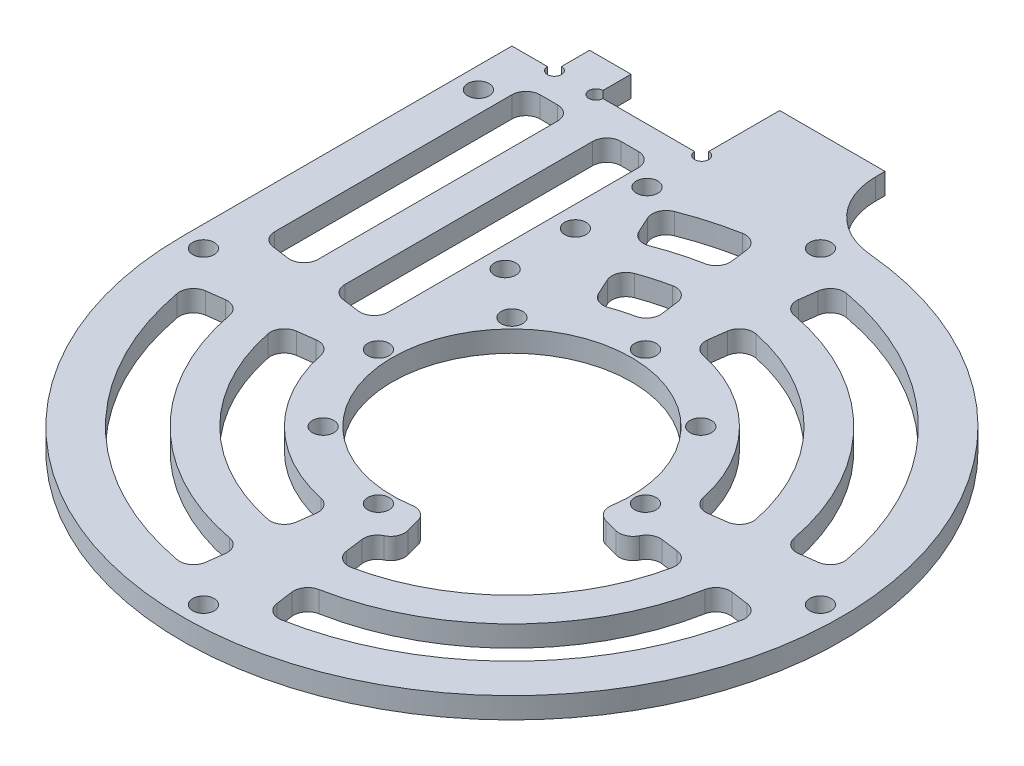
from build123d import *

# Parameters (mm, degrees)
SKETCH_1_R          = 1.525
SKETCH_1_R_2        = 17.025
EXTRUDE_1_DEPTH     = 3
CUT_EXTRUDE_2_DEPTH = 4
CUT_EXTRUDE_3_DEPTH = 4
FILLET_1_R          = 2
SKETCH_5_W          = 5.9
SKETCH_5_H          = 5
EXTRUDE_3_DEPTH     = 3
FILLET_3_R          = 10
SKETCH_6_R          = 1
CUT_EXTRUDE_7_DEPTH = 4.0000001


with BuildPart() as part:
    # 草图1 → 凸台-拉伸1 (new body)
    with BuildSketch(Plane(origin=(0, 0, 0), x_dir=(1, 0, 0), z_dir=(0, 1, 0))):
        with BuildLine():
            Line((-46.9, 0), (-46.9, 46.9))
            Line((-46.9, 46.9), (-16.9, 46.9))
            Line((-16.9, 46.9), (-16.9, 46.574671228))
            ThreePointArc((-16.9, 46.574671228), (-16.079234093, 44.95930534), (-14.290593047, 44.669776699))
            ThreePointArc((-14.290593047, 44.669776699), (37.88033008, -27.65303949), (-46.9, 0))
        make_face()
        with Locations((-19.9, 39.130550724)):
            Circle(SKETCH_1_R, mode=Mode.SUBTRACT)
        with Locations((0, 43.9)):
            Circle(SKETCH_1_R, mode=Mode.SUBTRACT)
        with Locations((43.9, 0)):
            Circle(SKETCH_1_R, mode=Mode.SUBTRACT)
        with Locations((0, -43.9)):
            Circle(SKETCH_1_R, mode=Mode.SUBTRACT)
        with Locations((-43.9, 0)):
            Circle(SKETCH_1_R, mode=Mode.SUBTRACT)
        Circle(SKETCH_1_R_2, mode=Mode.SUBTRACT)
        with Locations((0, 19)):
            Circle(SKETCH_1_R, mode=Mode.SUBTRACT)
        with Locations((13.435028843, 13.435028843)):
            Circle(SKETCH_1_R, mode=Mode.SUBTRACT)
        with Locations((19, 0)):
            Circle(SKETCH_1_R, mode=Mode.SUBTRACT)
        with Locations((13.435028843, -13.435028843)):
            Circle(SKETCH_1_R, mode=Mode.SUBTRACT)
        with Locations((0, -19)):
            Circle(SKETCH_1_R, mode=Mode.SUBTRACT)
        with Locations((-13.435028843, -13.435028843)):
            Circle(SKETCH_1_R, mode=Mode.SUBTRACT)
        with Locations((-19, 0)):
            Circle(SKETCH_1_R, mode=Mode.SUBTRACT)
        with Locations((-13.435028843, 13.435028843)):
            Circle(SKETCH_1_R, mode=Mode.SUBTRACT)
        with Locations((-43.9, 39.130550724)):
            Circle(SKETCH_1_R, mode=Mode.SUBTRACT)
        with Locations((-19.9, 28.931907268)):
            Circle(SKETCH_1_R, mode=Mode.SUBTRACT)
        with Locations((-19.9, 18.931907268)):
            Circle(SKETCH_1_R, mode=Mode.SUBTRACT)
    extrude(amount=EXTRUDE_1_DEPTH)

    # 草图2 → 切除-拉伸2 (cut, through all)
    with BuildSketch(Plane(origin=(0, 0, 0), x_dir=(1, 0, 0), z_dir=(0, 1, 0))):
        with BuildLine():
            Line((-40.9, 7.138540077), (-40.9, 40.9))
            ThreePointArc((-40.9, 40.9), (-40.314213562, 42.314213562), (-38.9, 42.9))
            Line((-38.9, 42.9), (-36.4, 42.9))
            ThreePointArc((-36.4, 42.9), (-34.985786438, 42.314213562), (-34.4, 40.9))
            Line((-34.4, 40.9), (-34.4, 6.809408833))
            ThreePointArc((-34.4, 6.809408833), (-35.08130837, 5.305729218), (-36.661052384, 4.826519111))
            Line((-36.661052384, 4.826519111), (-39.161052384, 5.155650355))
            ThreePointArc((-39.161052384, 5.155650355), (-40.403679615, 5.819848447), (-40.9, 7.138540077))
        make_face()
        with BuildLine():
            Line((-22.9, 40.9), (-22.9, 5.295405111))
            ThreePointArc((-22.9, 5.295405111), (-23.58130837, 3.791725496), (-25.161052384, 3.312515388))
            Line((-25.161052384, 3.312515388), (-27.661052384, 3.641646632))
            ThreePointArc((-27.661052384, 3.641646632), (-28.903679615, 4.305844725), (-29.4, 5.624536355))
            Line((-29.4, 5.624536355), (-29.4, 40.9))
            ThreePointArc((-29.4, 40.9), (-28.814213562, 42.314213562), (-27.4, 42.9))
            Line((-27.4, 42.9), (-24.9, 42.9))
            ThreePointArc((-24.9, 42.9), (-23.485786438, 42.314213562), (-22.9, 40.9))
        make_face()
        with BuildLine():
            Line((-16.052335707, 35.377005503), (-15.017866178, 33.097185612))
            ThreePointArc((-15.017866178, 33.097185612), (-13.951256671, 32.07143718), (-12.47150097, 32.059657883))
            ThreePointArc((-12.47150097, 32.059657883), (-9.454853527, 33.075152982), (-6.357257912, 33.807473609))
            ThreePointArc((-6.357257912, 33.807473609), (-5.107297521, 34.599568748), (-4.743976207, 36.034076785))
            Line((-4.743976207, 36.034076785), (-5.070753578, 38.516197348))
            ThreePointArc((-5.070753578, 38.516197348), (-5.877325942, 39.872636067), (-7.416298484, 40.221990463))
            ThreePointArc((-7.416298484, 40.221990463), (-11.241381083, 39.324818516), (-14.962731687, 38.064769282))
            ThreePointArc((-14.962731687, 38.064769282), (-16.084543492, 36.954803854), (-16.052335707, 35.377005503))
        make_face()
        with BuildLine():
            Line((-3.566877483, 27.093124313), (-3.239601191, 24.607214067))
            ThreePointArc((-3.239601191, 24.607214067), (-3.588130359, 23.193397362), (-4.803013732, 22.390646688))
            ThreePointArc((-4.803013732, 22.390646688), (-6.294074005, 22.018052421), (-7.756784033, 21.546282776))
            ThreePointArc((-7.756784033, 21.546282776), (-9.212394117, 21.585646975), (-10.255510362, 22.601648329))
            Line((-10.255510362, 22.601648329), (-11.291559312, 24.884949032))
            ThreePointArc((-11.291559312, 24.884949032), (-11.315535978, 26.482740298), (-10.161542784, 27.588096133))
            ThreePointArc((-10.161542784, 27.588096133), (-8.080601561, 28.267717956), (-5.954859703, 28.790617324))
            ThreePointArc((-5.954859703, 28.790617324), (-4.391004222, 28.462184914), (-3.566877483, 27.093124313))
        make_face()
        with BuildLine():
            Line((5.070753578, 38.516197348), (4.743976207, 36.034076785))
            ThreePointArc((4.743976207, 36.034076785), (5.107297521, 34.599568748), (6.357257912, 33.807473609))
            ThreePointArc((6.357257912, 33.807473609), (24.324473273, 24.324473273), (33.807473609, 6.357257912))
            ThreePointArc((33.807473609, 6.357257912), (34.599568748, 5.107297521), (36.034076785, 4.743976207))
            Line((36.034076785, 4.743976207), (38.516197348, 5.070753578))
            ThreePointArc((38.516197348, 5.070753578), (39.872636067, 5.877325942), (40.221990463, 7.416298484))
            ThreePointArc((40.221990463, 7.416298484), (28.920667351, 28.920667351), (7.416298484, 40.221990463))
            ThreePointArc((7.416298484, 40.221990463), (5.877325942, 39.872636067), (5.070753578, 38.516197348))
        make_face()
        with BuildLine():
            Line((3.566877483, 27.093124313), (3.239601191, 24.607214067))
            ThreePointArc((3.239601191, 24.607214067), (3.588130359, 23.193397362), (4.803013732, 22.390646688))
            ThreePointArc((4.803013732, 22.390646688), (16.192745289, 16.192745289), (22.390646688, 4.803013732))
            ThreePointArc((22.390646688, 4.803013732), (23.193397362, 3.588130359), (24.607214067, 3.239601191))
            Line((24.607214067, 3.239601191), (27.093124313, 3.566877483))
            ThreePointArc((27.093124313, 3.566877483), (28.462184914, 4.391004222), (28.790617324, 5.954859703))
            ThreePointArc((28.790617324, 5.954859703), (20.788939367, 20.788939367), (5.954859703, 28.790617324))
            ThreePointArc((5.954859703, 28.790617324), (4.391004222, 28.462184914), (3.566877483, 27.093124313))
        make_face()
        with BuildLine():
            Line((38.516197348, -5.070753578), (36.034076785, -4.743976207))
            ThreePointArc((36.034076785, -4.743976207), (34.599568748, -5.107297521), (33.807473609, -6.357257912))
            ThreePointArc((33.807473609, -6.357257912), (24.324473273, -24.324473273), (6.357257912, -33.807473609))
            ThreePointArc((6.357257912, -33.807473609), (5.107297521, -34.599568748), (4.743976207, -36.034076785))
            Line((4.743976207, -36.034076785), (5.070753578, -38.516197348))
            ThreePointArc((5.070753578, -38.516197348), (5.877325942, -39.872636067), (7.416298484, -40.221990463))
            ThreePointArc((7.416298484, -40.221990463), (28.920667351, -28.920667351), (40.221990463, -7.416298484))
            ThreePointArc((40.221990463, -7.416298484), (39.872636067, -5.877325942), (38.516197348, -5.070753578))
        make_face()
        with BuildLine():
            Line((27.093124313, -3.566877483), (24.607214067, -3.239601191))
            ThreePointArc((24.607214067, -3.239601191), (23.193397362, -3.588130359), (22.390646688, -4.803013732))
            ThreePointArc((22.390646688, -4.803013732), (16.192745289, -16.192745289), (4.803013732, -22.390646688))
            ThreePointArc((4.803013732, -22.390646688), (3.588130359, -23.193397362), (3.239601191, -24.607214067))
            Line((3.239601191, -24.607214067), (3.566877483, -27.093124313))
            ThreePointArc((3.566877483, -27.093124313), (4.391004222, -28.462184914), (5.954859703, -28.790617324))
            ThreePointArc((5.954859703, -28.790617324), (20.788939367, -20.788939367), (28.790617324, -5.954859703))
            ThreePointArc((28.790617324, -5.954859703), (28.462184914, -4.391004222), (27.093124313, -3.566877483))
        make_face()
        with BuildLine():
            Line((-5.070753578, -38.516197348), (-4.743976207, -36.034076785))
            ThreePointArc((-4.743976207, -36.034076785), (-5.107297521, -34.599568748), (-6.357257912, -33.807473609))
            ThreePointArc((-6.357257912, -33.807473609), (-24.324473273, -24.324473273), (-33.807473609, -6.357257912))
            ThreePointArc((-33.807473609, -6.357257912), (-34.599568748, -5.107297521), (-36.034076785, -4.743976207))
            Line((-36.034076785, -4.743976207), (-38.516197348, -5.070753578))
            ThreePointArc((-38.516197348, -5.070753578), (-39.872636067, -5.877325942), (-40.221990463, -7.416298484))
            ThreePointArc((-40.221990463, -7.416298484), (-28.920667351, -28.920667351), (-7.416298484, -40.221990463))
            ThreePointArc((-7.416298484, -40.221990463), (-5.877325942, -39.872636067), (-5.070753578, -38.516197348))
        make_face()
        with BuildLine():
            Line((-3.566877483, -27.093124313), (-3.239601191, -24.607214067))
            ThreePointArc((-3.239601191, -24.607214067), (-3.588130359, -23.193397362), (-4.803013732, -22.390646688))
            ThreePointArc((-4.803013732, -22.390646688), (-16.192745289, -16.192745289), (-22.390646688, -4.803013732))
            ThreePointArc((-22.390646688, -4.803013732), (-23.193397362, -3.588130359), (-24.607214067, -3.239601191))
            Line((-24.607214067, -3.239601191), (-27.093124313, -3.566877483))
            ThreePointArc((-27.093124313, -3.566877483), (-28.462184914, -4.391004222), (-28.790617324, -5.954859703))
            ThreePointArc((-28.790617324, -5.954859703), (-20.788939367, -20.788939367), (-5.954859703, -28.790617324))
            ThreePointArc((-5.954859703, -28.790617324), (-4.391004222, -28.462184914), (-3.566877483, -27.093124313))
        make_face()
    extrude(amount=CUT_EXTRUDE_2_DEPTH, mode=Mode.SUBTRACT)

    # 草图3 → 切除-拉伸3 (cut, through all)
    with BuildSketch(Plane(origin=(0, 3, 0), x_dir=(1, 0, 0), z_dir=(0, 1, 0))):
        with BuildLine():
            Line((0, 0), (5.926956133, -22.119701422))
            ThreePointArc((5.926956133, -22.119701422), (16.192745289, -16.192745289), (22.119701422, -5.926956133))
            Line((22.119701422, -5.926956133), (0, 0))
        make_face()
    extrude(amount=-CUT_EXTRUDE_3_DEPTH, mode=Mode.SUBTRACT)

    # 圆角1
    fillet_1_edges = [part.edges().sort_by_distance(p)[0] for p in [
        (5.926956133, 1.5, 22.119701422),
        (4.406394243, 1.5, 16.444887193),
        (16.444887193, 1.5, 4.406394243),
        (22.119701422, 1.5, 5.926956133),
    ]]
    fillet(fillet_1_edges, radius=FILLET_1_R)

    # 草图5 → 凸台-拉伸3 (add)
    with BuildSketch(Plane(origin=(0, 0, 0), x_dir=(1, 0, 0), z_dir=(0, 1, 0))):
        with Locations((-37.9, 49.4)):
            Rectangle(SKETCH_5_W, SKETCH_5_H)
        Polygon((-4.9, 43.9), (-19.9, 43.9), (-19.9, 46.9), (-19.9, 51.9), (-19.9, 58), (-4.9, 58), align=None)
    extrude(amount=EXTRUDE_3_DEPTH)

    # 圆角3
    fillet_3_edges = [part.edges().sort_by_distance(p)[0] for p in [
        (-4.9, 1.5, -46.643327497),
    ]]
    fillet(fillet_3_edges, radius=FILLET_3_R)

    # 草图6 → 切除-拉伸7 (cut, through all)
    with BuildSketch(Plane(origin=(0, 0, 0), x_dir=(1, 0, 0), z_dir=(0, 1, 0))):
        with Locations((-19.9, 46.9)):
            Circle(SKETCH_6_R)
        with Locations((-40.85, 46.9)):
            Circle(SKETCH_6_R)
        with Locations((-34.95, 46.9)):
            Circle(SKETCH_6_R)
    extrude(amount=CUT_EXTRUDE_7_DEPTH, mode=Mode.SUBTRACT)


solid = part.part
